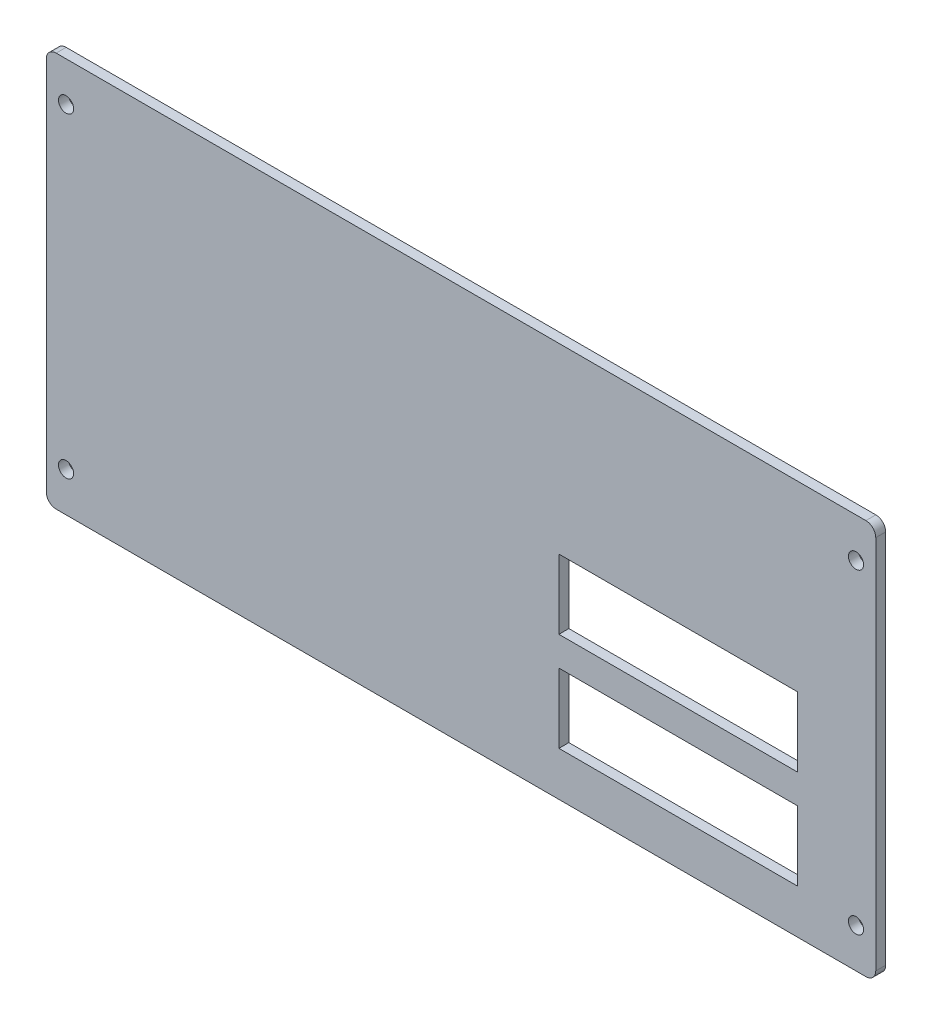
from build123d import *

# Parameters (mm, degrees)
SKETCH1_W             = 133.35
SKETCH1_H             = 63.5
BOSS_EXTRUDE1_DEPTH   = 1.6002
SKETCH2_W             = 38.3794
SKETCH2_H             = 11.176
CUT_EXTRUDE1_DEPTH    = 2.6002
F_2_CLEARANCE_HOLE1_D = 2.4384
FILLET1_R             = 1.5875
SKETCH5_W             = 0.284935898
SKETCH5_H             = 3.175
CUT_EXTRUDE2_DEPTH    = 0.2286


with BuildPart() as part:
    # Sketch1 → Boss-Extrude1 (new body)
    with BuildSketch(Plane.XY):
        Rectangle(SKETCH1_W, SKETCH1_H)
    extrude(amount=BOSS_EXTRUDE1_DEPTH)

    # Sketch2 → Cut-Extrude1 (cut, through all)
    with BuildSketch(Plane(origin=(0, 0, 0), x_dir=(-1, 0, 0), z_dir=(0, 0, -1))):
        with Locations((-34.925, -3.175)):
            Rectangle(SKETCH2_W, SKETCH2_H)
        with Locations((-34.925, -19.05)):
            Rectangle(SKETCH2_W, SKETCH2_H)
    extrude(amount=-CUT_EXTRUDE1_DEPTH, mode=Mode.SUBTRACT)

    # #2 Clearance Hole1 (through all)
    with Locations(Plane(origin=(0, 0, 0), x_dir=(-1, 0, 0), z_dir=(0, 0, -1))):
        with Locations((-63.5, 25.4), (63.5, 25.4), (63.5, -25.4), (-63.5, -25.4)):
            Hole(F_2_CLEARANCE_HOLE1_D / 2)

    # Fillet1
    fillet1_edges = [part.edges().sort_by_distance(p)[0] for p in [
        (66.675, -31.75, 0.8001),
        (-66.675, -31.75, 0.8001),
        (-66.675, 31.75, 0.8001),
        (66.675, 31.75, 0.8001),
    ]]
    fillet(fillet1_edges, radius=FILLET1_R)

    # Sketch5 → Cut-Extrude2 (cut)
    with BuildSketch(Plane(origin=(0, 0, 0), x_dir=(-1, 0, 0), z_dir=(0, 0, -1))):
        with BuildLine():
            Line((-8.978248718, -17.653), (-8.35558746, -17.653))
            add(Edge.make_bspline(
                [(-8.35558746, -17.653), (-8.312760424, -17.653047077), (-8.23070192, -17.65313728), (-8.113031834, -17.655872085), (-8.006161577, -17.65952487), (-7.910321589, -17.664588444), (-7.825216986, -17.670572494), (-7.751232864, -17.678965415), (-7.687787695, -17.687728683), (-7.649772559, -17.696638102), (-7.632435417, -17.700701322)],
                knots=[0, 0, 0, 0, 1.415646017, 2.712440637, 3.8905458, 4.950247383, 5.884950622, 6.709939814, 7.411656543, 8, 8, 8, 8], degree=3))
            add(Edge.make_bspline(
                [(-7.632435417, -17.700701322), (-7.610488425, -17.706708377), (-7.567111596, -17.718580937), (-7.504608507, -17.742360529), (-7.445141804, -17.770556493), (-7.388507462, -17.802691067), (-7.335401429, -17.840142972), (-7.285031378, -17.881394039), (-7.237841824, -17.927396676), (-7.194098133, -17.977634919), (-7.153925495, -18.031265395), (-7.119336426, -18.089088704), (-7.09037387, -18.150131529), (-7.065533331, -18.214351411), (-7.047654947, -18.282287633), (-7.034186688, -18.353468151), (-7.025638112, -18.427885334), (-7.024819359, -18.478739643), (-7.024402564, -18.504627604)],
                knots=[0, 0, 0, 0, 0.999701418, 1.975846123, 2.934577507, 3.890451536, 4.834027766, 5.787354733, 6.749476667, 7.726910423, 8.712836071, 9.690891519, 10.682875813, 11.679750201, 12.712814741, 13.765529915, 14.8625177, 16, 16, 16, 16], degree=3))
            add(Edge.make_bspline(
                [(-7.024402564, -18.504627604), (-7.024784857, -18.530733159), (-7.025532837, -18.58181044), (-7.034510182, -18.656534326), (-7.04660257, -18.727943151), (-7.065196325, -18.795878582), (-7.089549185, -18.859937173), (-7.118116976, -18.921097862), (-7.152573464, -18.978320136), (-7.19216556, -19.031811736), (-7.236208792, -19.08162287), (-7.284516814, -19.127392577), (-7.336894601, -19.168852941), (-7.393175693, -19.20609691), (-7.45390877, -19.238260821), (-7.518172723, -19.267069233), (-7.586526134, -19.291263695), (-7.633826843, -19.303990965), (-7.657876122, -19.310461939)],
                knots=[0, 0, 0, 0, 1.121902311, 2.195077645, 3.232258892, 4.234102512, 5.217864754, 6.176164875, 7.132989551, 8.084763148, 9.034132444, 9.988522005, 10.94243251, 11.903244335, 12.886203696, 13.894208494, 14.929344452, 16, 16, 16, 16], degree=3))
            add(Edge.make_bspline(
                [(-7.657876122, -19.310461939), (-7.677767346, -19.314691929), (-7.721360121, -19.323962198), (-7.793153876, -19.334311298), (-7.876742905, -19.343144693), (-7.972013116, -19.349767868), (-8.078878994, -19.355437845), (-8.197398349, -19.359944616), (-8.327803833, -19.362420983), (-8.418764176, -19.362548702), (-8.466254527, -19.362615385)],
                knots=[0, 0, 0, 0, 0.601384939, 1.31797006, 2.144135048, 3.087295005, 4.142315834, 5.309527816, 6.595305764, 8, 8, 8, 8], degree=3))
            Line((-8.466254527, -19.362615385), (-8.693312821, -19.362615385))
            Line((-8.693312821, -19.362615385), (-8.693312821, -20.828))
            Line((-8.693312821, -20.828), (-8.978248718, -20.828))
            Line((-8.978248718, -20.828), (-8.978248718, -17.653))
        make_face()
        with BuildLine():
            Line((-8.693312821, -17.978641026), (-8.693312821, -19.036974359))
            Line((-8.693312821, -19.036974359), (-8.137433413, -19.043970553))
            add(Edge.make_bspline(
                [(-8.137433413, -19.043970553), (-8.110291766, -19.043984581), (-8.057895377, -19.044011661), (-7.982206803, -19.040396494), (-7.911985521, -19.036223153), (-7.847447227, -19.030112709), (-7.788562829, -19.021475568), (-7.735234143, -19.012756348), (-7.687874679, -19.000142198), (-7.632448974, -18.9831577), (-7.570687652, -18.954190255), (-7.503497804, -18.912144284), (-7.446555915, -18.858549641), (-7.39728146, -18.798290109), (-7.358178271, -18.731253041), (-7.329552478, -18.65952622), (-7.312733, -18.583845242), (-7.310477667, -18.532058145), (-7.309338462, -18.505899639)],
                knots=[0, 0, 0, 0, 1.160613943, 2.240541288, 3.23993089, 4.169200891, 5.011653406, 5.7853311, 6.478053781, 7.106038997, 8.262395093, 9.384106736, 10.481365981, 11.59014053, 12.70357646, 13.786202915, 14.881775077, 16, 16, 16, 16], degree=3))
            add(Edge.make_bspline(
                [(-7.309338462, -18.505899639), (-7.310483862, -18.480373988), (-7.312760777, -18.429632152), (-7.32968431, -18.355265705), (-7.358122616, -18.284294744), (-7.397543956, -18.218097731), (-7.445387695, -18.158055031), (-7.500994956, -18.105896922), (-7.564234843, -18.063967235), (-7.623061453, -18.036904187), (-7.675313957, -18.02038033), (-7.720700092, -18.008818939), (-7.771945204, -17.99958821), (-7.829065976, -17.992113804), (-7.891619675, -17.985715307), (-7.960143718, -17.981373742), (-8.034378523, -17.978832421), (-8.085913826, -17.978706369), (-8.112628726, -17.978641026)],
                knots=[0, 0, 0, 0, 1.120700087, 2.227813068, 3.331159281, 4.466773991, 5.599788987, 6.693661531, 7.80175334, 8.91857717, 9.525282508, 10.207424825, 10.974604443, 11.810962634, 12.737642355, 13.736264703, 14.826523623, 16, 16, 16, 16], degree=3))
            Line((-8.112628726, -17.978641026), (-8.693312821, -17.978641026))
        make_face(mode=Mode.SUBTRACT)
        Polygon((-6.576646154, -17.653), (-6.282169992, -17.653), (-5.660780769, -19.981460537), (-4.736647155, -17.653), (-4.69530601, -17.653), (-3.788344872, -19.965560096), (-3.163775561, -17.653), (-2.872479487, -17.653), (-3.728559215, -20.828), (-3.769264343, -20.828), (-4.724562821, -18.399684696), (-5.691309615, -20.828), (-5.732014744, -20.828), align=None)
        with BuildLine():
            Line((-2.302607692, -17.653), (-1.667226082, -17.653))
            add(Edge.make_bspline(
                [(-1.667226082, -17.653), (-1.624825201, -17.653141139), (-1.543410813, -17.653412141), (-1.426776489, -17.654923226), (-1.320797622, -17.659254248), (-1.225529625, -17.66298132), (-1.140974245, -17.669777582), (-1.066872203, -17.676273311), (-1.003564792, -17.684776561), (-0.965241769, -17.692673623), (-0.947890144, -17.696249199)],
                knots=[0, 0, 0, 0, 1.410062039, 2.707475311, 3.878576406, 4.937260626, 5.877586885, 6.699081471, 7.410979367, 8, 8, 8, 8], degree=3))
            add(Edge.make_bspline(
                [(-0.947890144, -17.696249199), (-0.924661278, -17.701988479), (-0.87869908, -17.713344604), (-0.812522949, -17.737347242), (-0.749463527, -17.765123616), (-0.689782757, -17.797747848), (-0.633779575, -17.835462112), (-0.580876536, -17.877615338), (-0.53083358, -17.923976874), (-0.48567453, -17.975715623), (-0.443094105, -18.029995886), (-0.407181565, -18.088691437), (-0.376223973, -18.150070108), (-0.351576432, -18.214756123), (-0.331729985, -18.282122159), (-0.317736182, -18.352778424), (-0.309344033, -18.426403023), (-0.308489636, -18.476620555), (-0.30805641, -18.502083534)],
                knots=[0, 0, 0, 0, 1.027469482, 2.033020251, 3.019912614, 3.986113645, 4.951240523, 5.91722682, 6.890402269, 7.87763091, 8.8651537, 9.85103654, 10.82876324, 11.815024772, 12.821070561, 13.842952187, 14.906261191, 16, 16, 16, 16], degree=3))
            add(Edge.make_bspline(
                [(-0.30805641, -18.502083534), (-0.309389001, -18.544388236), (-0.311989232, -18.626935667), (-0.336232719, -18.746733752), (-0.375944276, -18.858484059), (-0.430666117, -18.96204588), (-0.500352355, -19.055400537), (-0.58410413, -19.137397593), (-0.681968163, -19.206013799), (-0.7730719, -19.253595987), (-0.853548353, -19.284069554), (-0.919800001, -19.305511108), (-0.99206933, -19.322077319), (-1.069663912, -19.336918296), (-1.152906657, -19.348123047), (-1.24159805, -19.356329601), (-1.335801345, -19.361458631), (-1.400516072, -19.362222449), (-1.433807612, -19.362615385)],
                knots=[0, 0, 0, 0, 1.260483769, 2.459530307, 3.627416485, 4.787058657, 5.939039949, 7.08810263, 8.267026773, 9.491475466, 10.141966685, 10.831826277, 11.566392101, 12.351337768, 13.187381173, 14.07005841, 15.007169909, 16, 16, 16, 16], degree=3))
            Line((-1.433807612, -19.362615385), (-0.267351282, -20.828))
            Line((-0.267351282, -20.828), (-0.619705048, -20.828))
            Line((-0.619705048, -20.828), (-1.786161378, -19.362615385))
            Line((-1.786161378, -19.362615385), (-2.017671795, -19.362615385))
            Line((-2.017671795, -19.362615385), (-2.017671795, -20.828))
            Line((-2.017671795, -20.828), (-2.302607692, -20.828))
            Line((-2.302607692, -20.828), (-2.302607692, -17.653))
        make_face()
        with BuildLine():
            Line((-2.017671795, -17.978641026), (-2.017671795, -19.036974359))
            Line((-2.017671795, -19.036974359), (-1.436351683, -19.041426482))
            add(Edge.make_bspline(
                [(-1.436351683, -19.041426482), (-1.409209933, -19.04143849), (-1.356601492, -19.041461764), (-1.280491603, -19.037838838), (-1.209625502, -19.0337174), (-1.144274248, -19.02741335), (-1.084408648, -19.019288914), (-1.030058623, -19.009126207), (-0.981135454, -18.997286121), (-0.924077494, -18.978960361), (-0.860362927, -18.94992633), (-0.791119388, -18.907684771), (-0.732152982, -18.854554212), (-0.682334635, -18.79379972), (-0.642302937, -18.727001123), (-0.614079859, -18.654959131), (-0.596170643, -18.579492467), (-0.59405832, -18.527623755), (-0.592992308, -18.501447516)],
                knots=[0, 0, 0, 0, 1.146690395, 2.22261258, 3.21895312, 4.145990853, 4.996080663, 5.770904154, 6.481378293, 7.121626537, 8.300444488, 9.431385265, 10.535395872, 11.636531494, 12.74115979, 13.810798291, 14.895190096, 16, 16, 16, 16], degree=3))
            add(Edge.make_bspline(
                [(-0.592992308, -18.501447516), (-0.594082803, -18.475914553), (-0.596243768, -18.425317536), (-0.613886579, -18.35124396), (-0.643721946, -18.281333227), (-0.683928548, -18.21586973), (-0.732913496, -18.15644667), (-0.790351797, -18.105603895), (-0.854672938, -18.063649024), (-0.914790383, -18.036838978), (-0.968524275, -18.020401683), (-1.015178324, -18.008834556), (-1.067893736, -17.999541359), (-1.126926474, -17.992095475), (-1.192024524, -17.985695633), (-1.263517044, -17.981385091), (-1.340929694, -17.978832514), (-1.39458441, -17.978706341), (-1.422359295, -17.978641026)],
                knots=[0, 0, 0, 0, 1.101028733, 2.181837193, 3.264309656, 4.369019818, 5.486613113, 6.575447106, 7.666700264, 8.788928104, 9.402425223, 10.0903467, 10.862060571, 11.710948788, 12.657782767, 13.684531032, 14.801375019, 16, 16, 16, 16], degree=3))
            Line((-1.422359295, -17.978641026), (-2.017671795, -17.978641026))
        make_face(mode=Mode.SUBTRACT)
        with Locations((1.747552564, -19.2405)):
            Rectangle(SKETCH5_W, SKETCH5_H)
        Polygon((2.704123077, -20.828), (2.704123077, -17.653), (2.763908734, -17.653), (4.861494872, -20.151913261), (4.861494872, -17.653), (5.146430769, -17.653), (5.146430769, -20.828), (5.081556971, -20.828), (2.989058974, -18.334810897), (2.989058974, -20.828), align=None)
        with BuildLine():
            Line((-8.978248718, -1.778), (-8.35558746, -1.778))
            add(Edge.make_bspline(
                [(-8.35558746, -1.778), (-8.312760424, -1.778047077), (-8.23070192, -1.77813728), (-8.113031834, -1.780872085), (-8.006161577, -1.78452487), (-7.910321589, -1.789588444), (-7.825216986, -1.795572494), (-7.751232864, -1.803965415), (-7.687787695, -1.812728683), (-7.649772559, -1.821638102), (-7.632435417, -1.825701322)],
                knots=[0, 0, 0, 0, 1.415646017, 2.712440637, 3.8905458, 4.950247383, 5.884950622, 6.709939814, 7.411656543, 8, 8, 8, 8], degree=3))
            add(Edge.make_bspline(
                [(-7.632435417, -1.825701322), (-7.610488425, -1.831708377), (-7.567111596, -1.843580937), (-7.504608507, -1.867360529), (-7.445141804, -1.895556493), (-7.388507462, -1.927691067), (-7.335401429, -1.965142972), (-7.285031378, -2.006394039), (-7.237841824, -2.052396676), (-7.194098133, -2.102634919), (-7.153925495, -2.156265395), (-7.119336426, -2.214088704), (-7.09037387, -2.275131529), (-7.065533331, -2.339351411), (-7.047654947, -2.407287633), (-7.034186688, -2.478468151), (-7.025638112, -2.552885334), (-7.024819359, -2.603739643), (-7.024402564, -2.629627604)],
                knots=[0, 0, 0, 0, 0.999701418, 1.975846123, 2.934577507, 3.890451536, 4.834027766, 5.787354733, 6.749476667, 7.726910423, 8.712836071, 9.690891519, 10.682875813, 11.679750201, 12.712814741, 13.765529915, 14.8625177, 16, 16, 16, 16], degree=3))
            add(Edge.make_bspline(
                [(-7.024402564, -2.629627604), (-7.024784857, -2.655733159), (-7.025532837, -2.70681044), (-7.034510182, -2.781534326), (-7.04660257, -2.852943151), (-7.065196325, -2.920878582), (-7.089549185, -2.984937173), (-7.118116976, -3.046097862), (-7.152573464, -3.103320136), (-7.19216556, -3.156811736), (-7.236208792, -3.20662287), (-7.284516814, -3.252392577), (-7.336894601, -3.293852941), (-7.393175693, -3.33109691), (-7.45390877, -3.363260821), (-7.518172723, -3.392069233), (-7.586526134, -3.416263695), (-7.633826843, -3.428990965), (-7.657876122, -3.435461939)],
                knots=[0, 0, 0, 0, 1.121902311, 2.195077645, 3.232258892, 4.234102512, 5.217864754, 6.176164875, 7.132989551, 8.084763148, 9.034132444, 9.988522005, 10.94243251, 11.903244335, 12.886203696, 13.894208494, 14.929344452, 16, 16, 16, 16], degree=3))
            add(Edge.make_bspline(
                [(-7.657876122, -3.435461939), (-7.677767346, -3.439691929), (-7.721360121, -3.448962198), (-7.793153876, -3.459311298), (-7.876742905, -3.468144693), (-7.972013116, -3.474767868), (-8.078878994, -3.480437845), (-8.197398349, -3.484944616), (-8.327803833, -3.487420983), (-8.418764176, -3.487548702), (-8.466254527, -3.487615385)],
                knots=[0, 0, 0, 0, 0.601384939, 1.31797006, 2.144135048, 3.087295005, 4.142315834, 5.309527816, 6.595305764, 8, 8, 8, 8], degree=3))
            Line((-8.466254527, -3.487615385), (-8.693312821, -3.487615385))
            Line((-8.693312821, -3.487615385), (-8.693312821, -4.953))
            Line((-8.693312821, -4.953), (-8.978248718, -4.953))
            Line((-8.978248718, -4.953), (-8.978248718, -1.778))
        make_face()
        with BuildLine():
            Line((-8.693312821, -2.103641026), (-8.693312821, -3.161974359))
            Line((-8.693312821, -3.161974359), (-8.137433413, -3.168970553))
            add(Edge.make_bspline(
                [(-8.137433413, -3.168970553), (-8.110291766, -3.168984581), (-8.057895377, -3.169011661), (-7.982206803, -3.165396494), (-7.911985521, -3.161223153), (-7.847447227, -3.155112709), (-7.788562829, -3.146475568), (-7.735234143, -3.137756348), (-7.687874679, -3.125142198), (-7.632448974, -3.1081577), (-7.570687652, -3.079190255), (-7.503497804, -3.037144284), (-7.446555915, -2.983549641), (-7.39728146, -2.923290109), (-7.358178271, -2.856253041), (-7.329552478, -2.78452622), (-7.312733, -2.708845242), (-7.310477667, -2.657058145), (-7.309338462, -2.630899639)],
                knots=[0, 0, 0, 0, 1.160613943, 2.240541288, 3.23993089, 4.169200891, 5.011653406, 5.7853311, 6.478053781, 7.106038997, 8.262395093, 9.384106736, 10.481365981, 11.59014053, 12.70357646, 13.786202915, 14.881775077, 16, 16, 16, 16], degree=3))
            add(Edge.make_bspline(
                [(-7.309338462, -2.630899639), (-7.310483862, -2.605373988), (-7.312760777, -2.554632152), (-7.32968431, -2.480265705), (-7.358122616, -2.409294744), (-7.397543956, -2.343097731), (-7.445387695, -2.283055031), (-7.500994956, -2.230896922), (-7.564234843, -2.188967235), (-7.623061453, -2.161904187), (-7.675313957, -2.14538033), (-7.720700092, -2.133818939), (-7.771945204, -2.12458821), (-7.829065976, -2.117113804), (-7.891619675, -2.110715307), (-7.960143718, -2.106373742), (-8.034378523, -2.103832421), (-8.085913826, -2.103706369), (-8.112628726, -2.103641026)],
                knots=[0, 0, 0, 0, 1.120700087, 2.227813068, 3.331159281, 4.466773991, 5.599788987, 6.693661531, 7.80175334, 8.91857717, 9.525282508, 10.207424825, 10.974604443, 11.810962634, 12.737642355, 13.736264703, 14.826523623, 16, 16, 16, 16], degree=3))
            Line((-8.112628726, -2.103641026), (-8.693312821, -2.103641026))
        make_face(mode=Mode.SUBTRACT)
        Polygon((-6.576646154, -1.778), (-6.282169992, -1.778), (-5.660780769, -4.106460537), (-4.736647155, -1.778), (-4.69530601, -1.778), (-3.788344872, -4.090560096), (-3.163775561, -1.778), (-2.872479487, -1.778), (-3.728559215, -4.953), (-3.769264343, -4.953), (-4.724562821, -2.524684696), (-5.691309615, -4.953), (-5.732014744, -4.953), align=None)
        with BuildLine():
            Line((-2.302607692, -1.778), (-1.667226082, -1.778))
            add(Edge.make_bspline(
                [(-1.667226082, -1.778), (-1.624825201, -1.778141139), (-1.543410813, -1.778412141), (-1.426776489, -1.779923226), (-1.320797622, -1.784254248), (-1.225529625, -1.78798132), (-1.140974245, -1.794777582), (-1.066872203, -1.801273311), (-1.003564792, -1.809776561), (-0.965241769, -1.817673623), (-0.947890144, -1.821249199)],
                knots=[0, 0, 0, 0, 1.410062039, 2.707475311, 3.878576406, 4.937260626, 5.877586885, 6.699081471, 7.410979367, 8, 8, 8, 8], degree=3))
            add(Edge.make_bspline(
                [(-0.947890144, -1.821249199), (-0.924661278, -1.826988479), (-0.87869908, -1.838344604), (-0.812522949, -1.862347242), (-0.749463527, -1.890123616), (-0.689782757, -1.922747848), (-0.633779575, -1.960462112), (-0.580876536, -2.002615338), (-0.53083358, -2.048976874), (-0.48567453, -2.100715623), (-0.443094105, -2.154995886), (-0.407181565, -2.213691437), (-0.376223973, -2.275070108), (-0.351576432, -2.339756123), (-0.331729985, -2.407122159), (-0.317736182, -2.477778424), (-0.309344033, -2.551403023), (-0.308489636, -2.601620555), (-0.30805641, -2.627083534)],
                knots=[0, 0, 0, 0, 1.027469482, 2.033020251, 3.019912614, 3.986113645, 4.951240523, 5.91722682, 6.890402269, 7.87763091, 8.8651537, 9.85103654, 10.82876324, 11.815024772, 12.821070561, 13.842952187, 14.906261191, 16, 16, 16, 16], degree=3))
            add(Edge.make_bspline(
                [(-0.30805641, -2.627083534), (-0.309389001, -2.669388236), (-0.311989232, -2.751935667), (-0.336232719, -2.871733752), (-0.375944276, -2.983484059), (-0.430666117, -3.08704588), (-0.500352355, -3.180400537), (-0.58410413, -3.262397593), (-0.681968163, -3.331013799), (-0.7730719, -3.378595987), (-0.853548353, -3.409069554), (-0.919800001, -3.430511108), (-0.99206933, -3.447077319), (-1.069663912, -3.461918296), (-1.152906657, -3.473123047), (-1.24159805, -3.481329601), (-1.335801345, -3.486458631), (-1.400516072, -3.487222449), (-1.433807612, -3.487615385)],
                knots=[0, 0, 0, 0, 1.260483769, 2.459530307, 3.627416485, 4.787058657, 5.939039949, 7.08810263, 8.267026773, 9.491475466, 10.141966685, 10.831826277, 11.566392101, 12.351337768, 13.187381173, 14.07005841, 15.007169909, 16, 16, 16, 16], degree=3))
            Line((-1.433807612, -3.487615385), (-0.267351282, -4.953))
            Line((-0.267351282, -4.953), (-0.619705048, -4.953))
            Line((-0.619705048, -4.953), (-1.786161378, -3.487615385))
            Line((-1.786161378, -3.487615385), (-2.017671795, -3.487615385))
            Line((-2.017671795, -3.487615385), (-2.017671795, -4.953))
            Line((-2.017671795, -4.953), (-2.302607692, -4.953))
            Line((-2.302607692, -4.953), (-2.302607692, -1.778))
        make_face()
        with BuildLine():
            Line((-2.017671795, -2.103641026), (-2.017671795, -3.161974359))
            Line((-2.017671795, -3.161974359), (-1.436351683, -3.166426482))
            add(Edge.make_bspline(
                [(-1.436351683, -3.166426482), (-1.409209933, -3.16643849), (-1.356601492, -3.166461764), (-1.280491603, -3.162838838), (-1.209625502, -3.1587174), (-1.144274248, -3.15241335), (-1.084408648, -3.144288914), (-1.030058623, -3.134126207), (-0.981135454, -3.122286121), (-0.924077494, -3.103960361), (-0.860362927, -3.07492633), (-0.791119388, -3.032684771), (-0.732152982, -2.979554212), (-0.682334635, -2.91879972), (-0.642302937, -2.852001123), (-0.614079859, -2.779959131), (-0.596170643, -2.704492467), (-0.59405832, -2.652623755), (-0.592992308, -2.626447516)],
                knots=[0, 0, 0, 0, 1.146690395, 2.22261258, 3.21895312, 4.145990853, 4.996080663, 5.770904154, 6.481378293, 7.121626537, 8.300444488, 9.431385265, 10.535395872, 11.636531494, 12.74115979, 13.810798291, 14.895190096, 16, 16, 16, 16], degree=3))
            add(Edge.make_bspline(
                [(-0.592992308, -2.626447516), (-0.594082803, -2.600914553), (-0.596243768, -2.550317536), (-0.613886579, -2.47624396), (-0.643721946, -2.406333227), (-0.683928548, -2.34086973), (-0.732913496, -2.28144667), (-0.790351797, -2.230603895), (-0.854672938, -2.188649024), (-0.914790383, -2.161838978), (-0.968524275, -2.145401683), (-1.015178324, -2.133834556), (-1.067893736, -2.124541359), (-1.126926474, -2.117095475), (-1.192024524, -2.110695633), (-1.263517044, -2.106385091), (-1.340929694, -2.103832514), (-1.39458441, -2.103706341), (-1.422359295, -2.103641026)],
                knots=[0, 0, 0, 0, 1.101028733, 2.181837193, 3.264309656, 4.369019818, 5.486613113, 6.575447106, 7.666700264, 8.788928104, 9.402425223, 10.0903467, 10.862060571, 11.710948788, 12.657782767, 13.684531032, 14.801375019, 16, 16, 16, 16], degree=3))
            Line((-1.422359295, -2.103641026), (-2.017671795, -2.103641026))
        make_face(mode=Mode.SUBTRACT)
        with BuildLine():
            add(Edge.make_bspline(
                [(3.090821795, -1.696589744), (3.149612005, -1.6980788), (3.265080829, -1.701003429), (3.434784486, -1.723390902), (3.596795751, -1.76212172), (3.752434377, -1.813704568), (3.89983872, -1.882515332), (4.040118287, -1.96568686), (4.172939308, -2.064090504), (4.296511561, -2.176965589), (4.409593223, -2.299777722), (4.509220992, -2.430839826), (4.592716501, -2.569359454), (4.661283608, -2.71492035), (4.715075918, -2.867193321), (4.752195336, -3.026990166), (4.775906372, -3.193275521), (4.778678399, -3.306692748), (4.780084615, -3.364227965)],
                knots=[0, 0, 0, 0, 1.065120563, 2.091984664, 3.0946048, 4.079830382, 5.057816894, 6.036188127, 7.030412546, 8.04752943, 9.064399622, 10.05169764, 11.02544977, 11.989514704, 12.962713494, 13.945757189, 14.957906945, 16, 16, 16, 16], degree=3))
            add(Edge.make_bspline(
                [(4.780084615, -3.364227965), (4.778678605, -3.421339363), (4.775907196, -3.533912544), (4.752168377, -3.699142668), (4.714938327, -3.857974943), (4.661783142, -4.010144214), (4.593542887, -4.155811004), (4.50949141, -4.294592026), (4.41048474, -4.426532778), (4.297811383, -4.550187839), (4.174983295, -4.663578401), (4.043238695, -4.762383382), (3.905540469, -4.847404552), (3.760116663, -4.915244027), (3.608895915, -4.969465698), (3.450524808, -5.006434155), (3.285745434, -5.030280259), (3.173376737, -5.033018484), (3.1162625, -5.034410256)],
                knots=[0, 0, 0, 0, 1.043624062, 2.057103931, 3.04512605, 4.022047818, 4.998200453, 5.980619268, 6.982898556, 8.009068085, 9.034988726, 10.034168286, 11.015286542, 11.987931943, 12.962482838, 13.94673481, 14.956375938, 16, 16, 16, 16], degree=3))
            add(Edge.make_bspline(
                [(3.1162625, -5.034410256), (3.058727582, -5.033004741), (2.945310943, -5.030234097), (2.778816633, -5.006483822), (2.618907536, -4.969344211), (2.466040946, -4.916267794), (2.320131617, -4.847672163), (2.180894185, -4.764029619), (2.04888753, -4.664781713), (1.925206089, -4.552144891), (1.812040745, -4.429524983), (1.713380454, -4.298139623), (1.629719101, -4.160566459), (1.561353792, -4.016423705), (1.507229604, -3.866408182), (1.470304519, -3.709519206), (1.446414048, -3.546651226), (1.443661009, -3.435759454), (1.442264103, -3.379492388)],
                knots=[0, 0, 0, 0, 1.053102029, 2.075944431, 3.073151272, 4.055350789, 5.033113405, 6.020478099, 7.024410459, 8.052272461, 9.079885166, 10.07527673, 11.055994387, 12.023226415, 12.992069828, 13.970394897, 14.97016774, 16, 16, 16, 16], degree=3))
            add(Edge.make_bspline(
                [(1.442264103, -3.379492388), (1.442749093, -3.341725609), (1.443712957, -3.266668497), (1.455316849, -3.155210939), (1.472154964, -3.045545842), (1.496286699, -2.937985053), (1.527847711, -2.832791874), (1.565087764, -2.729240825), (1.610571767, -2.628381304), (1.661989212, -2.529735513), (1.719376709, -2.434841199), (1.782763996, -2.345143291), (1.849924652, -2.259889101), (1.923551445, -2.181287891), (2.001217791, -2.107053074), (2.084183606, -2.038325466), (2.171942642, -1.974485332), (2.264872515, -1.916954023), (2.360683378, -1.864921094), (2.45945017, -1.820269843), (2.559831488, -1.78194663), (2.66229749, -1.75088531), (2.766576076, -1.726363392), (2.872894838, -1.709665292), (2.981169075, -1.698031804), (3.054113628, -1.697072499), (3.090821795, -1.696589744)],
                knots=[0, 0, 0, 0, 1.037015668, 2.060948919, 3.074880161, 4.083647147, 5.086022904, 6.090072063, 7.104153813, 8.122640571, 9.144368836, 10.147691507, 11.138137339, 12.123020368, 13.103399296, 14.087645067, 15.080126199, 16.082011238, 17.087798457, 18.072939717, 19.057185487, 20.037253025, 21.01195951, 21.997135196, 22.992090687, 24, 24, 24, 24], degree=3))
        make_face()
        with BuildLine():
            add(Edge.make_bspline(
                [(3.104814183, -2.022230769), (3.074683765, -2.022598063), (3.014710979, -2.023329138), (2.925552864, -2.032959108), (2.837567324, -2.046684079), (2.750736188, -2.066261601), (2.665422768, -2.092935278), (2.580831841, -2.123633816), (2.497734785, -2.161027234), (2.416405928, -2.20327533), (2.337561539, -2.250037565), (2.263164302, -2.301719097), (2.193021618, -2.357107928), (2.127305226, -2.416333324), (2.066208092, -2.479696891), (2.008527684, -2.546238029), (1.956575992, -2.617858673), (1.908964076, -2.692616685), (1.866357535, -2.770414691), (1.828470392, -2.850433638), (1.797478755, -2.933326253), (1.7722036, -3.018193239), (1.751248771, -3.104900185), (1.737973711, -3.194104848), (1.728237928, -3.285358985), (1.72754864, -3.347028238), (1.7272, -3.378220353)],
                knots=[0, 0, 0, 0, 1.008559885, 2.007477868, 2.99961109, 3.989939068, 4.984837346, 5.991145699, 7.001802488, 8.033829008, 9.059044045, 10.069351652, 11.065060232, 12.050310815, 13.029377138, 14.011219647, 14.996725999, 15.989392538, 16.977580475, 17.965360261, 18.951710183, 19.937753436, 20.929683414, 21.935841486, 22.955955122, 24, 24, 24, 24], degree=3))
            add(Edge.make_bspline(
                [(1.7272, -3.378220353), (1.728356482, -3.42408751), (1.73063164, -3.514322398), (1.750550293, -3.646554929), (1.781231655, -3.773635017), (1.826459409, -3.89486732), (1.883020324, -4.01129392), (1.952894717, -4.121881986), (2.035679745, -4.226661408), (2.129717372, -4.324900688), (2.232517256, -4.414567953), (2.341676233, -4.493274759), (2.456024862, -4.559868343), (2.575861339, -4.614120087), (2.700545892, -4.65710935), (2.830881956, -4.686572108), (2.966001302, -4.705962699), (3.05810411, -4.707824842), (3.104814183, -4.708769231)],
                knots=[0, 0, 0, 0, 1.032063989, 2.030389145, 3.003944642, 3.970395727, 4.937377036, 5.913328081, 6.909231446, 7.93887556, 8.970685674, 9.976071282, 10.964166581, 11.944589148, 12.933237628, 13.927779006, 14.949070134, 16, 16, 16, 16], degree=3))
            add(Edge.make_bspline(
                [(3.104814183, -4.708769231), (3.136209945, -4.70833788), (3.198477171, -4.707482383), (3.291092395, -4.698865726), (3.382039101, -4.685048245), (3.471189726, -4.665154007), (3.558443091, -4.64025547), (3.644163377, -4.610675602), (3.72743754, -4.573771939), (3.809316107, -4.532997726), (3.887689841, -4.486515583), (3.962506931, -4.436588118), (4.031881569, -4.38128087), (4.097548799, -4.322935425), (4.158896774, -4.260375363), (4.215510638, -4.193682019), (4.267199758, -4.122434423), (4.314793594, -4.047789805), (4.35725084, -3.969778919), (4.394243308, -3.889469854), (4.425626928, -3.807060362), (4.450962071, -3.722431579), (4.470815311, -3.635744238), (4.484494953, -3.546882267), (4.494063894, -3.456023435), (4.494785142, -3.394570079), (4.495148718, -3.363591947)],
                knots=[0, 0, 0, 0, 1.047197238, 2.076906641, 3.100256066, 4.114471768, 5.12198147, 6.126382909, 7.136867548, 8.15857795, 9.17633901, 10.174870724, 11.156907918, 12.133735059, 13.104061851, 14.077631395, 15.04955518, 16.038496417, 17.029181396, 18.010275684, 18.986308667, 19.968651475, 20.955262928, 21.950658345, 22.966943676, 24, 24, 24, 24], degree=3))
            add(Edge.make_bspline(
                [(4.495148718, -3.363591947), (4.494784851, -3.33282574), (4.494063054, -3.2717953), (4.484499524, -3.181570129), (4.470800859, -3.093347573), (4.451058974, -3.00747398), (4.425613477, -2.923927461), (4.394237828, -2.842786483), (4.357239734, -2.763748763), (4.314777988, -2.687009651), (4.26704792, -2.613372567), (4.214892427, -2.542976093), (4.157411005, -2.477142249), (4.096245968, -2.414245776), (4.029869522, -2.355628119), (3.958582341, -2.301269833), (3.883249862, -2.249859077), (3.803487298, -2.203480888), (3.721169568, -2.160650834), (3.636701907, -2.123955996), (3.551041223, -2.092775573), (3.46440535, -2.066180898), (3.376065077, -2.046760756), (3.286617318, -2.03294674), (3.196185826, -2.02333249), (3.135368048, -2.022599175), (3.104814183, -2.022230769)],
                knots=[0, 0, 0, 0, 1.02996197, 2.043119294, 3.035359645, 4.018872909, 4.991431989, 5.957985074, 6.929999688, 7.912076566, 8.892894881, 9.867085534, 10.843653904, 11.817741046, 12.803660682, 13.806313499, 14.818574707, 15.856120519, 16.894564902, 17.924820532, 18.937903209, 19.946497019, 20.957711757, 21.963978472, 22.977135795, 24, 24, 24, 24], degree=3))
        make_face(mode=Mode.SUBTRACT)
        with BuildLine():
            Line((5.431366667, -1.778), (5.716302564, -1.778))
            Line((5.716302564, -1.778), (5.716302564, -3.680328726))
            add(Edge.make_bspline(
                [(5.716302564, -3.680328726), (5.716260161, -3.707253393), (5.716179693, -3.75834759), (5.716717187, -3.831071691), (5.718222472, -3.895725993), (5.719171488, -3.952559716), (5.721282712, -4.001312065), (5.723004512, -4.042247168), (5.725218445, -4.075171195), (5.727879202, -4.094385321), (5.729022917, -4.102644431)],
                knots=[0, 0, 0, 0, 1.528628734, 2.90083645, 4.128790002, 5.200304208, 6.127813768, 6.898992206, 7.526736466, 8, 8, 8, 8], degree=3))
            add(Edge.make_bspline(
                [(5.729022917, -4.102644431), (5.733719611, -4.132441138), (5.742848359, -4.190355614), (5.766113287, -4.272822412), (5.798604878, -4.347145949), (5.837106781, -4.415645478), (5.88784565, -4.476414397), (5.948627428, -4.532395682), (6.022267261, -4.581355819), (6.104146525, -4.626124056), (6.192398133, -4.662105952), (6.282578353, -4.689314218), (6.373331627, -4.705895791), (6.434088577, -4.707815795), (6.464259295, -4.708769231)],
                knots=[0, 0, 0, 0, 1.035780045, 2.013197591, 2.933192213, 3.817615948, 4.702609284, 5.640816605, 6.646850145, 7.73207398, 8.84249596, 9.914020372, 10.964143139, 12, 12, 12, 12], degree=3))
            add(Edge.make_bspline(
                [(6.464259295, -4.708769231), (6.490161617, -4.707795095), (6.541816655, -4.70585245), (6.618566774, -4.693822438), (6.693315444, -4.67214121), (6.766431775, -4.644165144), (6.834967311, -4.607201258), (6.898960291, -4.564501282), (6.956077574, -4.51441713), (7.008200186, -4.458990389), (7.053589021, -4.396452142), (7.092932842, -4.328164117), (7.125159935, -4.253098638), (7.141074419, -4.200344269), (7.14925028, -4.173242388)],
                knots=[0, 0, 0, 0, 0.994687771, 1.983630487, 2.973142513, 3.978332533, 4.983357753, 5.956394766, 6.925816176, 7.893390482, 8.871859704, 9.88551698, 10.913711441, 12, 12, 12, 12], degree=3))
            add(Edge.make_bspline(
                [(7.14925028, -4.173242388), (7.151971823, -4.162040467), (7.158036516, -4.137078072), (7.163703478, -4.094876616), (7.169605826, -4.045084122), (7.173701186, -3.987342834), (7.177693721, -3.921846238), (7.180082295, -3.848253133), (7.181186317, -3.766830747), (7.18151532, -3.710009893), (7.181687179, -3.680328726)],
                knots=[0, 0, 0, 0, 0.558680831, 1.244966039, 2.062412453, 2.990489873, 4.051219941, 5.244515665, 6.560634259, 8, 8, 8, 8], degree=3))
            Line((7.181687179, -3.680328726), (7.181687179, -1.778))
            Line((7.181687179, -1.778), (7.466623077, -1.778))
            Line((7.466623077, -1.778), (7.466623077, -3.695593149))
            add(Edge.make_bspline(
                [(7.466623077, -3.695593149), (7.466392553, -3.730153821), (7.465942673, -3.797601075), (7.462041436, -3.896435522), (7.455821157, -3.990191441), (7.447032677, -4.078881434), (7.435387682, -4.162188135), (7.422438017, -4.240841747), (7.405946584, -4.314277676), (7.386684856, -4.383068512), (7.36466528, -4.448551085), (7.336143667, -4.510698185), (7.304008585, -4.571399105), (7.265895292, -4.629735746), (7.223067824, -4.685966405), (7.174579513, -4.739750066), (7.122034025, -4.791946201), (7.064557853, -4.841215911), (7.003098448, -4.886399496), (6.937838629, -4.926130332), (6.869279702, -4.959716042), (6.79759988, -4.987362059), (6.722768575, -5.008148874), (6.644783899, -5.023638479), (6.563468345, -5.032439849), (6.508164692, -5.033747886), (6.480159736, -5.034410256)],
                knots=[0, 0, 0, 0, 1.316592851, 2.569410997, 3.76748051, 4.895814652, 5.963796859, 6.97159953, 7.931736103, 8.829262218, 9.692595152, 10.560224239, 11.431080259, 12.30701507, 13.211635791, 14.121146779, 15.063487852, 16.031507147, 17.00238618, 17.966455255, 18.938106653, 19.907068911, 20.888905087, 21.893141452, 22.933117798, 24, 24, 24, 24], degree=3))
            add(Edge.make_bspline(
                [(6.480159736, -5.034410256), (6.44961705, -5.033698362), (6.389692409, -5.032301628), (6.301392877, -5.024298134), (6.21674357, -5.009222876), (6.134850453, -4.990027784), (6.056828459, -4.963553965), (5.981632263, -4.932622095), (5.910549745, -4.894633437), (5.842427736, -4.852366574), (5.779086707, -4.804809938), (5.720941206, -4.752975637), (5.667895237, -4.697694009), (5.62084292, -4.638366534), (5.579004689, -4.575454629), (5.54296371, -4.508780318), (5.512018124, -4.438369417), (5.496046452, -4.389426157), (5.487972236, -4.364683694)],
                knots=[0, 0, 0, 0, 1.13879206, 2.234305948, 3.301075583, 4.341971843, 5.366689343, 6.369221514, 7.369726634, 8.367512178, 9.355451585, 10.318319045, 11.268648973, 12.207971039, 13.137398894, 14.081662264, 15.030215811, 16, 16, 16, 16], degree=3))
            add(Edge.make_bspline(
                [(5.487972236, -4.364683694), (5.483275814, -4.347781287), (5.473089169, -4.31111959), (5.462180507, -4.25044399), (5.453010125, -4.180580457), (5.444387226, -4.101524211), (5.4392991, -4.013213975), (5.434838281, -3.91568803), (5.431335241, -3.80882845), (5.431355899, -3.734393282), (5.431366667, -3.695593149)],
                knots=[0, 0, 0, 0, 0.625038921, 1.35572334, 2.194682327, 3.136881307, 4.189498639, 5.346923369, 6.617055217, 8, 8, 8, 8], degree=3))
            Line((5.431366667, -3.695593149), (5.431366667, -1.778))
        make_face()
        Polygon((7.914379487, -2.103641026), (7.914379487, -1.778), (9.583289744, -1.778), (9.583289744, -2.103641026), (8.891302564, -2.103641026), (8.891302564, -4.953), (8.606366667, -4.953), (8.606366667, -2.103641026), align=None)
    extrude(amount=-CUT_EXTRUDE2_DEPTH, mode=Mode.SUBTRACT)


solid = part.part
